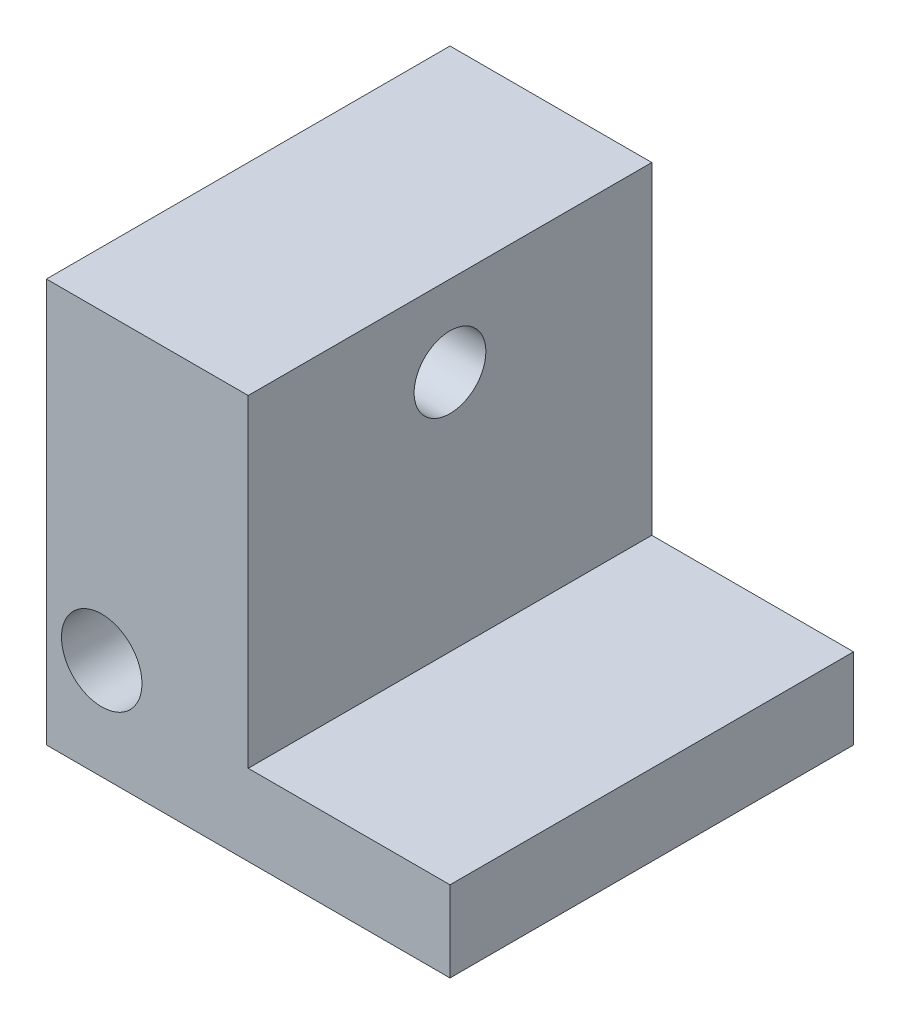
from build123d import *

# Parameters (mm, degrees)
SKETCH1_W                 = 10
SKETCH1_H                 = 10
EXTRUDE1_DEPTH            = 10
SKETCH2_W                 = 5
SKETCH2_H                 = 8
EXTRUDE2_DEPTH            = 11
SKETCH4_R                 = 1.25
CUT_EXTRUDE1_DEPTH        = 4.5
F_3_48_TAPPED_HOLE1_D     = 1.9939
F_3_48_TAPPED_HOLE1_DEPTH = 5
F_3_48_TAPPED_HOLE1_TIP   = 0.599027994
F_2_56_TAPPED_HOLE1_D     = 1.778
F_2_56_TAPPED_HOLE1_DEPTH = 5.73
F_2_56_TAPPED_HOLE1_TIP   = 0.53416509


with BuildPart() as part:
    # Sketch1 → Extrude1 (new body)
    with BuildSketch(Plane.XY):
        with Locations((5, 5)):
            Rectangle(SKETCH1_W, SKETCH1_H)
    extrude(amount=EXTRUDE1_DEPTH)

    # Sketch2 → Extrude2 (cut, through all)
    with BuildSketch(Plane.XY.offset(10)):
        with Locations((7.5, 6)):
            Rectangle(SKETCH2_W, SKETCH2_H)
    extrude(amount=-EXTRUDE2_DEPTH, mode=Mode.SUBTRACT)

    # Sketch4 → Cut-Extrude1 (cut)
    with BuildSketch(Plane.ZY):
        with Locations((5, 2.5)):
            Circle(SKETCH4_R)
    extrude(amount=-CUT_EXTRUDE1_DEPTH, mode=Mode.SUBTRACT)

    # #3-48 Tapped Hole1
    with Locations(Plane.XY.offset(10)):
        with Locations((1.37, 2.5)):
            Hole(F_3_48_TAPPED_HOLE1_D / 2, depth=F_3_48_TAPPED_HOLE1_DEPTH)
            with Locations((0, 0, -(F_3_48_TAPPED_HOLE1_DEPTH + F_3_48_TAPPED_HOLE1_TIP / 2))):  # 118° drill point
                Cone(0, F_3_48_TAPPED_HOLE1_D / 2, F_3_48_TAPPED_HOLE1_TIP, mode=Mode.SUBTRACT)

    # #2-56 Tapped Hole1
    with Locations(Plane(origin=(5, 0, 0), x_dir=(0, 0, -1), z_dir=(1, 0, 0))):
        with Locations((-5, 8)):
            Hole(F_2_56_TAPPED_HOLE1_D / 2, depth=F_2_56_TAPPED_HOLE1_DEPTH)
            with Locations((0, 0, -(F_2_56_TAPPED_HOLE1_DEPTH + F_2_56_TAPPED_HOLE1_TIP / 2))):  # 118° drill point
                Cone(0, F_2_56_TAPPED_HOLE1_D / 2, F_2_56_TAPPED_HOLE1_TIP, mode=Mode.SUBTRACT)


solid = part.part
